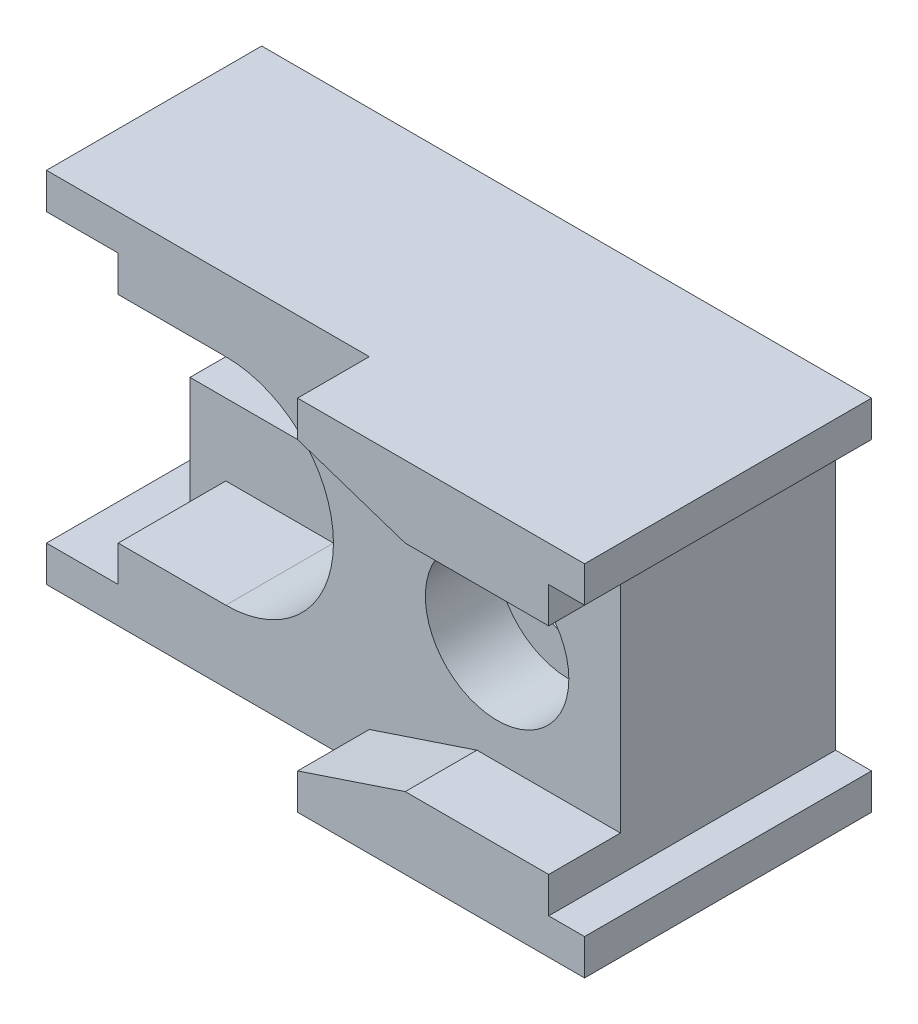
from build123d import *

# Parameters (mm, degrees)
BOSS_EXTRUDE1_DEPTH = 8
CUT_EXTRUDE1_DEPTH  = 2
SKETCH4_R           = 2
CUT_EXTRUDE2_DEPTH  = 2
SKETCH5_R           = 1
CUT_EXTRUDE3_DEPTH  = 22
CUT_EXTRUDE4_DEPTH  = 3


with BuildPart() as part:
    # Sketch1 → Boss-Extrude1 (new body)
    with BuildSketch(Plane.XY):
        with BuildLine():
            Line((8.5, 4), (8.5, 5))
            Line((8.5, 5), (-8.5, 5))
            Line((-8.5, 5), (-8.5, 4))
            Line((-8.5, 4), (-7.5, 4))
            Line((-7.5, 4), (-7.5, 1))
            Line((-7.5, 1), (-3.5, 1))
            ThreePointArc((-3.5, 1), (-2.5, 0), (-3.5, -1))
            Line((-3.5, -1), (-7.5, -1))
            Line((-7.5, -1), (-7.5, -4))
            Line((-7.5, -4), (-8.5, -4))
            Line((-8.5, -4), (-8.5, -5))
            Line((-8.5, -5), (8.5, -5))
            Line((8.5, -5), (8.5, -4))
            Line((8.5, -4), (7.5, -4))
            Line((7.5, -4), (7.5, 4))
            Line((7.5, 4), (8.5, 4))
        make_face()
    extrude(amount=BOSS_EXTRUDE1_DEPTH)

    # Sketch3 → Cut-Extrude1 (cut)
    with BuildSketch(Plane.XY.offset(8)):
        with BuildLine():
            Line((0.5, 4), (0.5, 5))
            Line((0.5, 5), (-8.5, 5))
            Line((-8.5, 5), (-8.5, 4))
            Line((-8.5, 4), (-7.5, 4))
            Line((-7.5, 4), (-7.5, 1))
            Line((-7.5, 1), (-3.5, 1))
            ThreePointArc((-3.5, 1), (-2.5, 0), (-3.5, -1))
            Line((-3.5, -1), (-7.5, -1))
            Line((-7.5, -1), (-7.5, -4))
            Line((-7.5, -4), (-8.5, -4))
            Line((-8.5, -4), (-8.5, -5))
            Line((-8.5, -5), (0.5, -5))
            Line((0.5, -5), (0.5, -4))
            Line((0.5, -4), (3.5, -3))
            Line((3.5, -3), (7.5, -3))
            Line((7.5, -3), (7.5, 3))
            Line((7.5, 3), (3.5, 3))
            Line((3.5, 3), (0.5, 4))
        make_face()
    extrude(amount=-CUT_EXTRUDE1_DEPTH, mode=Mode.SUBTRACT)

    # Sketch4 → Cut-Extrude2 (cut)
    with BuildSketch(Plane.XY.offset(6)):
        with Locations((4.062000401, 0)):
            Circle(SKETCH4_R)
    extrude(amount=-CUT_EXTRUDE2_DEPTH, mode=Mode.SUBTRACT)

    # Sketch5 → Cut-Extrude3 (cut)
    with BuildSketch(Plane.XY.offset(4)):
        with Locations((4.062000401, 0)):
            Circle(SKETCH5_R)
    extrude(amount=-CUT_EXTRUDE3_DEPTH, mode=Mode.SUBTRACT)

    # Sketch6 → Cut-Extrude4 (cut)
    with BuildSketch(Plane.XY.offset(6)):
        with BuildLine():
            Line((-6.5, 3), (-6.5, 4))
            Line((-6.5, 4), (-7.5, 4))
            Line((-7.5, 4), (-7.5, -4))
            Line((-7.5, -4), (-6.5, -4))
            Line((-6.5, -4), (-6.5, -3))
            Line((-6.5, -3), (-3.5, -3))
            ThreePointArc((-3.5, -3), (-0.5, 0), (-3.5, 3))
            Line((-3.5, 3), (-6.5, 3))
        make_face()
    extrude(amount=-CUT_EXTRUDE4_DEPTH, mode=Mode.SUBTRACT)


solid = part.part
